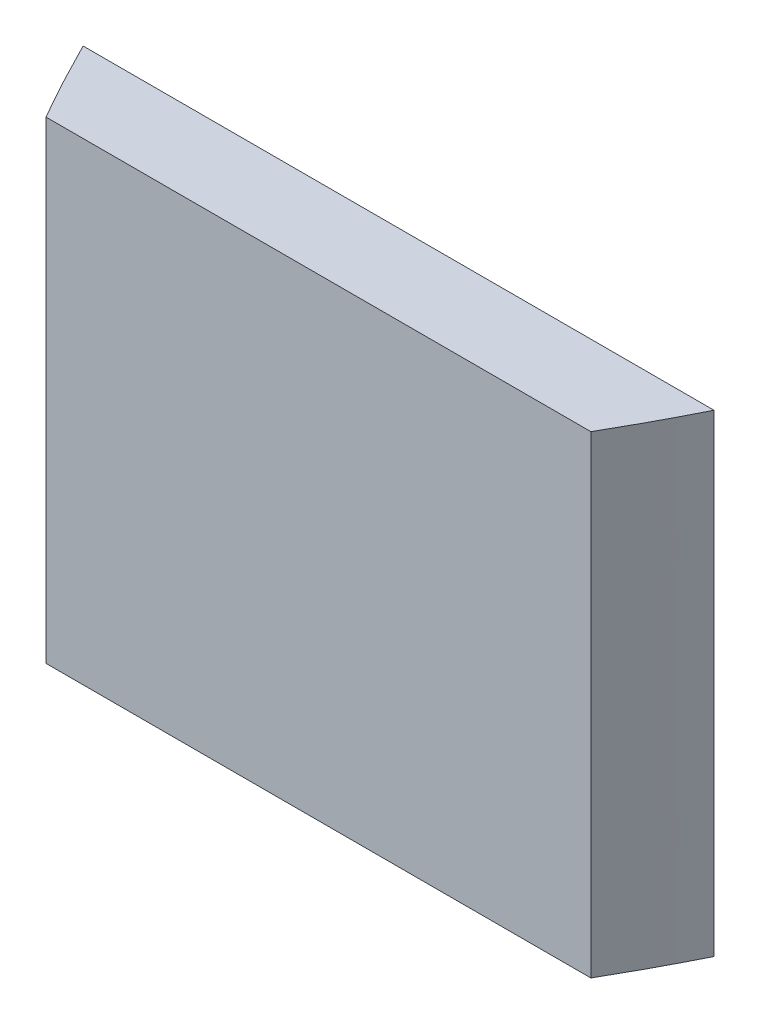
from build123d import *

# Parameters (mm, degrees)
BOSS_EXTRUDE1_DEPTH = 300
SKETCH7_W           = 461.235922443
SKETCH7_H           = 200
CUT_EXTRUDE5_DEPTH  = 350


with BuildPart() as part:
    # Sketch1 → Boss-Extrude1 (new body)
    with BuildSketch(Plane(origin=(0, 0, 0), x_dir=(1, 0, 0), z_dir=(0, 1, 0))):
        with BuildLine():
            Line((-200, 1e-09), (200, 1e-09))
            add(Edge.make_bspline(
                [(-200, 1e-09), (0, -400.000000001), (200, 1e-09)],
                knots=[0.056028396, 0.056028396, 0.056028396, 0.943971604, 0.943971604, 0.943971604], degree=2))
        make_face()
    extrude(amount=BOSS_EXTRUDE1_DEPTH)

    # Sketch7 → Cut-Extrude5 (cut)
    with BuildSketch(Plane(origin=(0, 300, 0), x_dir=(1, 0, 0), z_dir=(0, 1, 0))):
        with Locations((11.287443399, -150.799999999)):
            Rectangle(SKETCH7_W, SKETCH7_H)
    extrude(amount=-CUT_EXTRUDE5_DEPTH, mode=Mode.SUBTRACT)


solid = part.part
